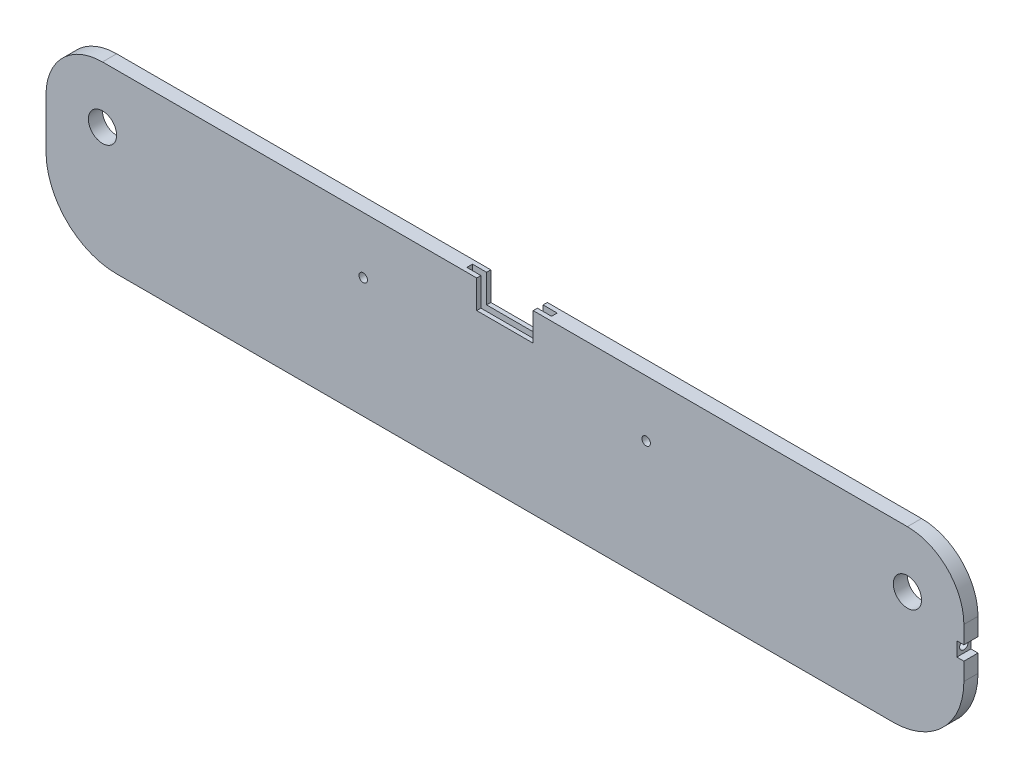
from build123d import *

# Parameters (mm, degrees)
SKETCH1_W           = 650
SKETCH1_H           = 125
BOSS_EXTRUDE1_DEPTH = 10
SKETCH2_R           = 10
CUT_EXTRUDE2_DEPTH  = 10
SKETCH3_R           = 10
CUT_EXTRUDE3_DEPTH  = 10
SKETCH8_R           = 3
CUT_EXTRUDE5_DEPTH  = 20
CUT_EXTRUDE7_DEPTH  = 30
CUT_EXTRUDE8_DEPTH  = 30
BOSS_EXTRUDE5_DEPTH = 20
SKETCH12_W          = 10
SKETCH12_H          = 10
CUT_EXTRUDE9_DEPTH  = 5
SKETCH13_R          = 3
CUT_EXTRUDE10_DEPTH = 5
FILLET3_R           = 50
FILLET5_R           = 40
FILLET6_R           = 50
FILLET7_R           = 40
SKETCH14_W          = 133
SKETCH14_H          = 20
CUT_EXTRUDE11_DEPTH = 80


with BuildPart() as part:
    # Sketch1 → Boss-Extrude1 (new body)
    with BuildSketch(Plane.XY):
        with Locations((277.89592831, 25.809681948)):
            Rectangle(SKETCH1_W, SKETCH1_H)
    extrude(amount=BOSS_EXTRUDE1_DEPTH)

    # Sketch2 → Cut-Extrude2 (cut)
    with BuildSketch(Plane.XY.offset(10)):
        with Locations((-7.10407169, 48.309681948)):
            Circle(SKETCH2_R)
    extrude(amount=-CUT_EXTRUDE2_DEPTH, mode=Mode.SUBTRACT)

    # Sketch3 → Cut-Extrude3 (cut)
    with BuildSketch(Plane.XY.offset(10)):
        with Locations((562.89592831, 48.309681948)):
            Circle(SKETCH3_R)
    extrude(amount=-CUT_EXTRUDE3_DEPTH, mode=Mode.SUBTRACT)

    # Sketch8 → Cut-Extrude5 (cut)
    with BuildSketch(Plane.XY.offset(10)):
        with Locations((177.509070801, 48.309681948)):
            Circle(SKETCH8_R)
        with Locations((377.89592831, 48.309681948)):
            Circle(SKETCH8_R)
    extrude(amount=-CUT_EXTRUDE5_DEPTH, mode=Mode.SUBTRACT)

    # Sketch10 → Cut-Extrude7 (cut)
    with BuildSketch(Plane(origin=(0, 88.309681948, 0), x_dir=(1, 0, 0), z_dir=(0, 1, 0))):
        Polygon((277.89592831, -3), (307.89592831, -3), (307.89592831, -7), (277.89592831, -7), (247.89592831, -7), (247.89592831, -3), align=None)
    extrude(amount=-CUT_EXTRUDE7_DEPTH, mode=Mode.SUBTRACT)

    # Sketch9 → Cut-Extrude8 (cut)
    with BuildSketch(Plane.XY.offset(10)):
        Polygon((277.89592831, 68.309681948), (257.89592831, 68.309681948), (257.89592831, 88.309681948), (297.89592831, 88.309681948), (297.89592831, 68.309681948), align=None)
    extrude(amount=-CUT_EXTRUDE8_DEPTH, mode=Mode.SUBTRACT)

    # Sketch7 → Boss-Extrude5 (add)
    with BuildSketch(Plane.XY.offset(10)):
        Polygon((160.89592831, 25.309681948), (158.89592831, 25.309681948), (158.89592831, -34.690318052), (98.89592831, -34.690318052), (98.89592831, 25.309681948), (96.89592831, 25.309681948), (96.89592831, -36.690318052), (160.89592831, -36.690318052), align=None)
        Polygon((89.89592831, 25.309681948), (91.89592831, 25.309681948), (91.89592831, -36.690318052), (27.89592831, -36.690318052), (27.89592831, 25.309681948), (29.89592831, 25.309681948), (29.89592831, -34.690318052), (89.89592831, -34.690318052), align=None)
    extrude(amount=BOSS_EXTRUDE5_DEPTH)

    # Sketch12 → Cut-Extrude9 (cut)
    with BuildSketch(Plane(origin=(602.89592831, 0, 0), x_dir=(0, 0, -1), z_dir=(1, 0, 0))):
        with Locations((-5, 30.809681948)):
            Rectangle(SKETCH12_W, SKETCH12_H)
    extrude(amount=-CUT_EXTRUDE9_DEPTH, mode=Mode.SUBTRACT)

    # Sketch13 → Cut-Extrude10 (cut)
    with BuildSketch(Plane(origin=(597.89592831, 0, 0), x_dir=(0, 0, -1), z_dir=(1, 0, 0))):
        with Locations((-5, 30.809681948)):
            Circle(SKETCH13_R)
    extrude(amount=-CUT_EXTRUDE10_DEPTH, mode=Mode.SUBTRACT)

    # Fillet3
    fillet3_edges = [part.edges().sort_by_distance(p)[0] for p in [
        (602.89592831, -36.690318052, 5),
    ]]
    fillet(fillet3_edges, radius=FILLET3_R)

    # Fillet5
    fillet5_edges = [part.edges().sort_by_distance(p)[0] for p in [
        (602.89592831, 88.309681948, 5),
    ]]
    fillet(fillet5_edges, radius=FILLET5_R)

    # Fillet6
    fillet6_edges = [part.edges().sort_by_distance(p)[0] for p in [
        (-47.10407169, -36.690318052, 5),
    ]]
    fillet(fillet6_edges, radius=FILLET6_R)

    # Fillet7
    fillet7_edges = [part.edges().sort_by_distance(p)[0] for p in [
        (-47.10407169, 88.309681948, 5),
    ]]
    fillet(fillet7_edges, radius=FILLET7_R)

    # Sketch14 → Cut-Extrude11 (cut)
    with BuildSketch(Plane.XZ.offset(36.690318052)):
        with Locations((94.39592831, 20)):
            Rectangle(SKETCH14_W, SKETCH14_H)
    extrude(amount=-CUT_EXTRUDE11_DEPTH, mode=Mode.SUBTRACT)


solid = part.part
